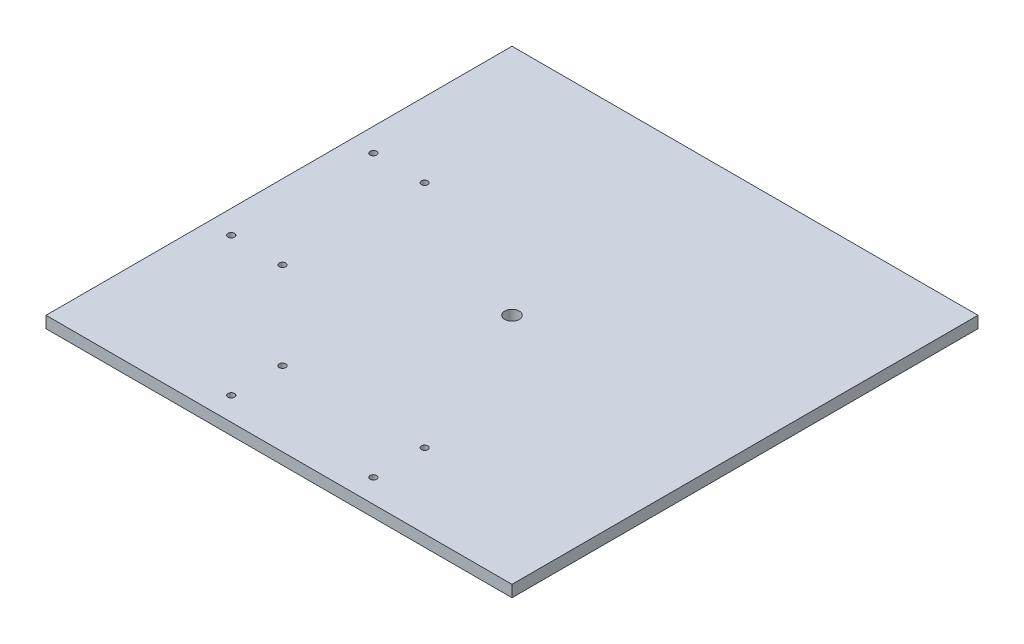
from build123d import *

# Parameters (mm, degrees)
SKETCH1_W                        = 508
SKETCH1_H                        = 508
BOSS_EXTRUDE1_DEPTH              = 12.7
K_0_281_DIAMETER_HOLE1_D         = 7.1374
K_0_281_DIAMETER_HOLE1_DEPTH     = 12.7
F_5_8_0_625_DIAMETER_HOLE1_D     = 15.875
F_5_8_0_625_DIAMETER_HOLE1_DEPTH = 25.4
F_5_8_0_625_DIAMETER_HOLE1_TIP   = 4.769331164


with BuildPart() as part:
    # Sketch1 → Boss-Extrude1 (new body)
    with BuildSketch(Plane(origin=(0, 0, 0), x_dir=(1, 0, 0), z_dir=(0, 1, 0))):
        Rectangle(SKETCH1_W, SKETCH1_H)
    extrude(amount=BOSS_EXTRUDE1_DEPTH)

    # K _0.281_ Diameter Hole1
    with Locations(Plane(origin=(0, 12.7, 0), x_dir=(1, 0, 0), z_dir=(0, 1, 0))):
        with Locations((-77.47, -228.6), (-77.47, -172.72), (77.47, -172.72), (77.47, -228.6), (-228.6, -77.47), (-172.72, -77.47), (-172.72, 77.47), (-228.6, 77.47)):
            Hole(K_0_281_DIAMETER_HOLE1_D / 2, depth=K_0_281_DIAMETER_HOLE1_DEPTH)

    # 5_8 _0.625_ Diameter Hole1
    with Locations(Plane(origin=(0, 12.7, 0), x_dir=(1, 0, 0), z_dir=(0, 1, 0))):
        with Locations((0, 0)):
            Hole(F_5_8_0_625_DIAMETER_HOLE1_D / 2, depth=F_5_8_0_625_DIAMETER_HOLE1_DEPTH)
            with Locations((0, 0, -(F_5_8_0_625_DIAMETER_HOLE1_DEPTH + F_5_8_0_625_DIAMETER_HOLE1_TIP / 2))):  # 118° drill point
                Cone(0, F_5_8_0_625_DIAMETER_HOLE1_D / 2, F_5_8_0_625_DIAMETER_HOLE1_TIP, mode=Mode.SUBTRACT)


solid = part.part
